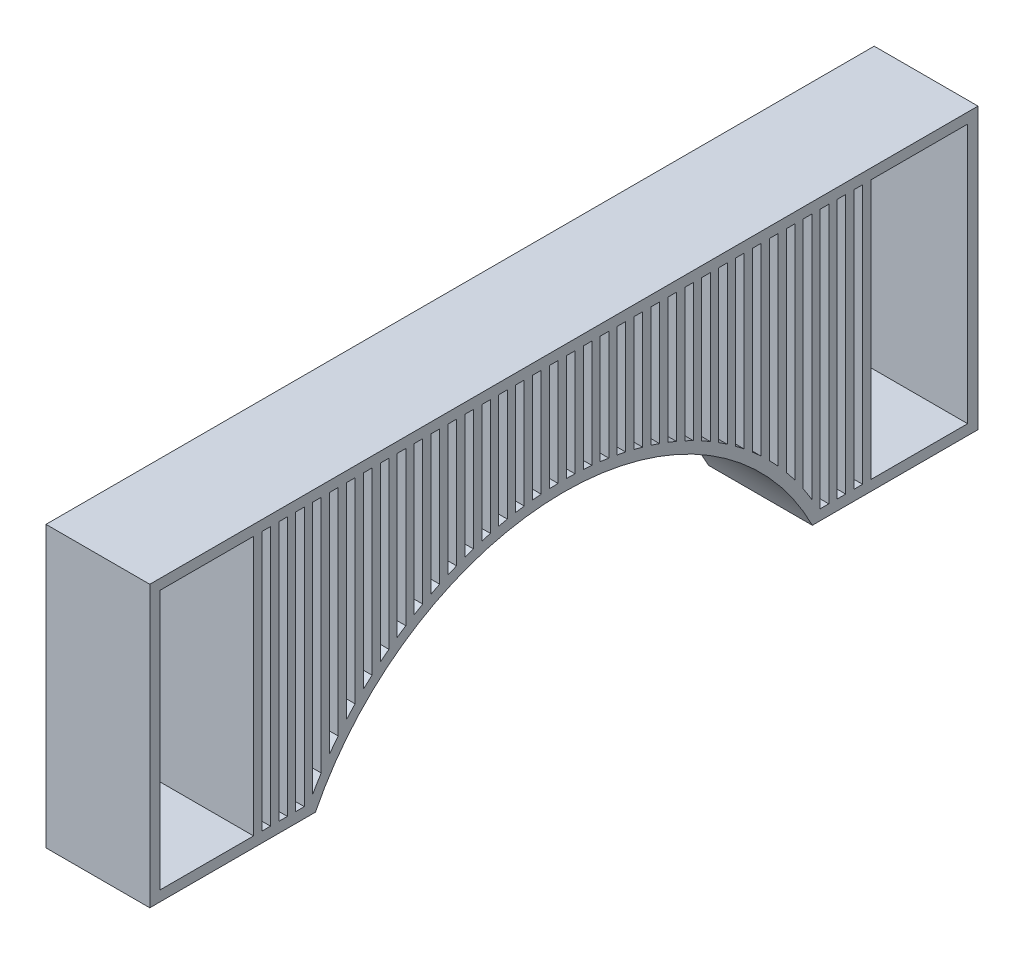
from build123d import *

# Parameters (mm, degrees)
SKETCH1_W           = 9
SKETCH1_H           = 25
SKETCH1_W_2         = 0.83
SKETCH1_W_3         = 9.32
BOSS_EXTRUDE1_DEPTH = 10


with BuildPart() as part:
    # Sketch1 → Boss-Extrude1 (new body)
    with BuildSketch(Plane(origin=(0, 0, 0), x_dir=(0, 0, -1), z_dir=(1, 0, 0))):
        with BuildLine():
            Line((23.938201687, 1), (39.9, 1))
            Line((39.9, 1), (39.9, 28))
            Line((39.9, 28), (-39.9, 28))
            Line((-39.9, 28), (-39.9, 1))
            Line((-39.9, 1), (-23.938201687, 1))
            ThreePointArc((-23.938201687, 1), (0, 15.75), (23.938201687, 1))
        make_face()
        with Locations((-34.4, 14.5)):
            Rectangle(SKETCH1_W, SKETCH1_H, mode=Mode.SUBTRACT)
        with Locations((-28.685, 14.5)):
            Rectangle(SKETCH1_W_2, SKETCH1_H, mode=Mode.SUBTRACT)
        with Locations((-27.055, 14.5)):
            Rectangle(SKETCH1_W_2, SKETCH1_H, mode=Mode.SUBTRACT)
        with Locations((-25.425, 14.5)):
            Rectangle(SKETCH1_W_2, SKETCH1_H, mode=Mode.SUBTRACT)
        with BuildLine():
            Line((-24.21, 27), (-23.38, 27))
            Line((-23.38, 27), (-23.38, 3.990465418))
            ThreePointArc((-23.38, 3.990465418), (-23.80494512, 3.308432638), (-24.21, 2.614402658))
            Line((-24.21, 2.614402658), (-24.21, 27))
        make_face(mode=Mode.SUBTRACT)
        with BuildLine():
            Line((-22.58, 27), (-21.75, 27))
            Line((-21.75, 27), (-21.75, 6.264083863))
            ThreePointArc((-21.75, 6.264083863), (-22.171789507, 5.720562008), (-22.58, 5.166769099))
            Line((-22.58, 5.166769099), (-22.58, 27))
        make_face(mode=Mode.SUBTRACT)
        with BuildLine():
            Line((-20.95, 27), (-20.12, 27))
            Line((-20.12, 27), (-20.12, 8.133993328))
            ThreePointArc((-20.12, 8.133993328), (-20.540040569, 7.683572361), (-20.95, 7.223956879))
            Line((-20.95, 7.223956879), (-20.95, 27))
        make_face(mode=Mode.SUBTRACT)
        with BuildLine():
            Line((-19.32, 27), (-18.49, 27))
            Line((-18.49, 27), (-18.49, 9.709573695))
            ThreePointArc((-18.49, 9.709573695), (-18.908921242, 9.328731498), (-19.32, 8.939437211))
            Line((-19.32, 8.939437211), (-19.32, 27))
        make_face(mode=Mode.SUBTRACT)
        with BuildLine():
            Line((-17.69, 27), (-16.86, 27))
            Line((-16.86, 27), (-16.86, 11.053854867))
            ThreePointArc((-16.86, 11.053854867), (-17.278137213, 10.72856686), (-17.69, 10.39537013))
            Line((-17.69, 10.39537013), (-17.69, 27))
        make_face(mode=Mode.SUBTRACT)
        with BuildLine():
            Line((-16.06, 27), (-15.23, 27))
            Line((-15.23, 27), (-15.23, 12.206979598))
            ThreePointArc((-15.23, 12.206979598), (-15.647552225, 11.928122407), (-16.06, 11.641769433))
            Line((-16.06, 11.641769433), (-16.06, 27))
        make_face(mode=Mode.SUBTRACT)
        with BuildLine():
            Line((-14.43, 27), (-13.6, 27))
            Line((-13.6, 27), (-13.6, 13.196236821))
            ThreePointArc((-13.6, 13.196236821), (-14.017094411, 12.957520994), (-14.43, 12.711630836))
            Line((-14.43, 12.711630836), (-14.43, 27))
        make_face(mode=Mode.SUBTRACT)
        with BuildLine():
            Line((-12.8, 27), (-11.97, 27))
            Line((-11.97, 27), (-11.97, 14.041016321))
            ThreePointArc((-11.97, 14.041016321), (-12.386722167, 13.83793109), (-12.8, 13.627925359))
            Line((-12.8, 13.627925359), (-12.8, 27))
        make_face(mode=Mode.SUBTRACT)
        with BuildLine():
            Line((-11.17, 27), (-10.34, 27))
            Line((-10.34, 27), (-10.34, 14.755511039))
            ThreePointArc((-10.34, 14.755511039), (-10.756409627, 14.584735262), (-11.17, 14.40724062))
            Line((-11.17, 14.40724062), (-11.17, 27))
        make_face(mode=Mode.SUBTRACT)
        with BuildLine():
            Line((-9.54, 27), (-8.71, 27))
            Line((-8.71, 27), (-8.71, 15.350301135))
            ThreePointArc((-8.71, 15.350301135), (-9.126139757, 15.209352108), (-9.54, 15.061844056))
            Line((-9.54, 15.061844056), (-9.54, 27))
        make_face(mode=Mode.SUBTRACT)
        with BuildLine():
            Line((-7.91, 27), (-7.08, 27))
            Line((-7.08, 27), (-7.08, 15.833333127))
            ThreePointArc((-7.08, 15.833333127), (-7.495900758, 15.720346875), (-7.91, 15.600926813))
            Line((-7.91, 15.600926813), (-7.91, 27))
        make_face(mode=Mode.SUBTRACT)
        with BuildLine():
            Line((-6.28, 27), (-5.45, 27))
            Line((-5.45, 27), (-5.45, 16.210548417))
            ThreePointArc((-5.45, 16.210548417), (-5.865684067, 16.124137529), (-6.28, 16.031388443))
            Line((-6.28, 16.031388443), (-6.28, 27))
        make_face(mode=Mode.SUBTRACT)
        with BuildLine():
            Line((-4.65, 27), (-3.82, 27))
            Line((-3.82, 27), (-3.82, 16.486296047))
            ThreePointArc((-3.82, 16.486296047), (-4.235483175, 16.425455998), (-4.65, 16.358347269))
            Line((-4.65, 16.358347269), (-4.65, 27))
        make_face(mode=Mode.SUBTRACT)
        with BuildLine():
            Line((-3.02, 27), (-2.19, 27))
            Line((-2.19, 27), (-2.19, 16.663604962))
            ThreePointArc((-2.19, 16.663604962), (-2.605292879, 16.62765252), (-3.02, 16.585477199))
            Line((-3.02, 16.585477199), (-3.02, 27))
        make_face(mode=Mode.SUBTRACT)
        with BuildLine():
            Line((-1.39, 27), (-0.56, 27))
            Line((-0.56, 27), (-0.56, 16.74435914))
            ThreePointArc((-0.56, 16.74435914), (-0.97510879, 16.732893349), (-1.39, 16.715228254))
            Line((-1.39, 16.715228254), (-1.39, 27))
        make_face(mode=Mode.SUBTRACT)
        with BuildLine():
            Line((0.24, 27), (1.07, 27))
            Line((1.07, 27), (1.07, 16.729400641))
            ThreePointArc((1.07, 16.729400641), (0.655073035, 16.74228093), (0.24, 16.748964009))
            Line((0.24, 16.748964009), (0.24, 27))
        make_face(mode=Mode.SUBTRACT)
        with BuildLine():
            Line((1.87, 27), (2.7, 27))
            Line((2.7, 27), (2.7, 16.618574231))
            ThreePointArc((2.7, 16.618574231), (2.285256378, 16.655912786), (1.87, 16.687034809))
            Line((1.87, 16.687034809), (1.87, 27))
        make_face(mode=Mode.SUBTRACT)
        with BuildLine():
            Line((3.5, 27), (4.33, 27))
            Line((4.33, 27), (4.33, 16.410719219))
            ThreePointArc((4.33, 16.410719219), (3.915445127, 16.472886648), (3.5, 16.528796203))
            Line((3.5, 16.528796203), (3.5, 27))
        make_face(mode=Mode.SUBTRACT)
        with BuildLine():
            Line((5.13, 27), (5.96, 27))
            Line((5.96, 27), (5.96, 16.103607495))
            ThreePointArc((5.96, 16.103607495), (5.54564356, 16.191252495), (5.13, 16.272574915))
            Line((5.13, 16.272574915), (5.13, 27))
        make_face(mode=Mode.SUBTRACT)
        with BuildLine():
            Line((6.76, 27), (7.59, 27))
            Line((7.59, 27), (7.59, 15.693819847))
            ThreePointArc((7.59, 15.693819847), (7.175856686, 15.807905369), (6.76, 15.915578058))
            Line((6.76, 15.915578058), (6.76, 27))
        make_face(mode=Mode.SUBTRACT)
        with BuildLine():
            Line((8.39, 27), (9.22, 27))
            Line((9.22, 27), (9.22, 15.176543806))
            ThreePointArc((9.22, 15.176543806), (8.806090708, 15.3184047), (8.39, 15.453733699))
            Line((8.39, 15.453733699), (8.39, 27))
        make_face(mode=Mode.SUBTRACT)
        with BuildLine():
            Line((10.02, 27), (10.85, 27))
            Line((10.85, 27), (10.85, 14.545263234))
            ThreePointArc((10.85, 14.545263234), (10.43635371, 14.71669403), (10.02, 14.881440377))
            Line((10.02, 14.881440377), (10.02, 27))
        make_face(mode=Mode.SUBTRACT)
        with BuildLine():
            Line((11.65, 27), (12.48, 27))
            Line((12.48, 27), (12.48, 13.791288211))
            ThreePointArc((12.48, 13.791288211), (12.066656732, 13.994675988), (11.65, 14.191186581))
            Line((11.65, 14.191186581), (11.65, 27))
        make_face(mode=Mode.SUBTRACT)
        with BuildLine():
            Line((13.28, 27), (14.11, 27))
            Line((14.11, 27), (14.11, 12.903035298))
            ThreePointArc((14.11, 12.903035298), (13.697015562, 13.141563916), (13.28, 13.372972792))
            Line((13.28, 13.372972792), (13.28, 27))
        make_face(mode=Mode.SUBTRACT)
        with BuildLine():
            Line((14.91, 27), (15.74, 27))
            Line((15.74, 27), (15.74, 11.864894719))
            ThreePointArc((15.74, 11.864894719), (15.327453929, 12.142868646), (14.91, 12.413416205))
            Line((14.91, 12.413416205), (14.91, 27))
        make_face(mode=Mode.SUBTRACT)
        with BuildLine():
            Line((16.54, 27), (17.37, 27))
            Line((17.37, 27), (17.37, 10.655370303))
            ThreePointArc((17.37, 10.655370303), (16.958009538, 10.978751951), (16.54, 11.294314713))
            Line((16.54, 11.294314713), (16.54, 27))
        make_face(mode=Mode.SUBTRACT)
        with BuildLine():
            Line((18.17, 27), (19, 27))
            Line((19, 27), (19, 9.24384143))
            ThreePointArc((19, 9.24384143), (18.588746526, 9.621199835), (18.17, 9.990225759))
            Line((18.17, 9.990225759), (18.17, 27))
        make_face(mode=Mode.SUBTRACT)
        with BuildLine():
            Line((19.8, 27), (20.63, 27))
            Line((20.63, 27), (20.63, 7.584460014))
            ThreePointArc((20.63, 7.584460014), (20.219784013, 8.028792794), (19.8, 8.464097468))
            Line((19.8, 8.464097468), (19.8, 27))
        make_face(mode=Mode.SUBTRACT)
        with BuildLine():
            Line((21.43, 27), (22.26, 27))
            Line((22.26, 27), (22.26, 5.603299973))
            ThreePointArc((22.26, 5.603299973), (21.851371771, 6.135969619), (21.43, 6.658616547))
            Line((21.43, 6.658616547), (21.43, 27))
        make_face(mode=Mode.SUBTRACT)
        with BuildLine():
            Line((23.06, 27), (23.89, 27))
            Line((23.89, 27), (23.89, 3.166465806))
            ThreePointArc((23.89, 3.166465806), (23.484138497, 3.827339784), (23.06, 4.47663518))
            Line((23.06, 4.47663518), (23.06, 27))
        make_face(mode=Mode.SUBTRACT)
        with Locations((25.105, 14.5)):
            Rectangle(SKETCH1_W_2, SKETCH1_H, mode=Mode.SUBTRACT)
        with Locations((26.735, 14.5)):
            Rectangle(SKETCH1_W_2, SKETCH1_H, mode=Mode.SUBTRACT)
        with Locations((28.365, 14.5)):
            Rectangle(SKETCH1_W_2, SKETCH1_H, mode=Mode.SUBTRACT)
        with Locations((34.24, 14.5)):
            Rectangle(SKETCH1_W_3, SKETCH1_H, mode=Mode.SUBTRACT)
    extrude(amount=BOSS_EXTRUDE1_DEPTH)


solid = part.part
